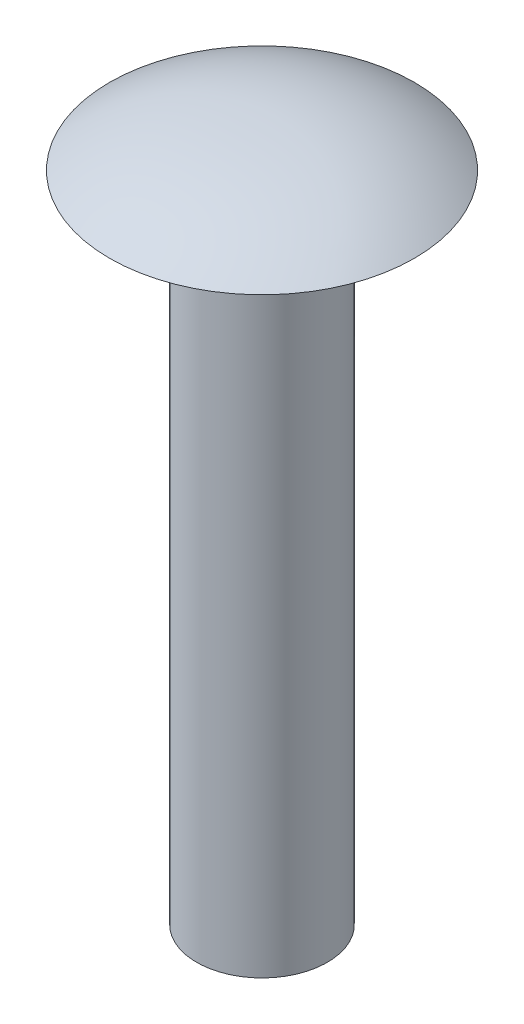
from build123d import *


with BuildPart() as part:
    # Szkic1 → Obrót1 (revolve)
    with BuildSketch(Plane.XY):
        with BuildLine():
            Line((0, 0), (0, 32))
            add(Edge.make_bspline(
                [(0, 32), (2.666666667, 32), (4.815594549, 31.529537164), (7, 30)],
                knots=[0, 0, 0, 0, 1, 1, 1, 1], degree=3))
            Line((7, 30), (3, 30))
            Line((3, 30), (3, 0))
            Line((3, 0), (0, 0))
        make_face()
    revolve(axis=Axis((0, 0, 0), (0, 1, 0)))


solid = part.part
